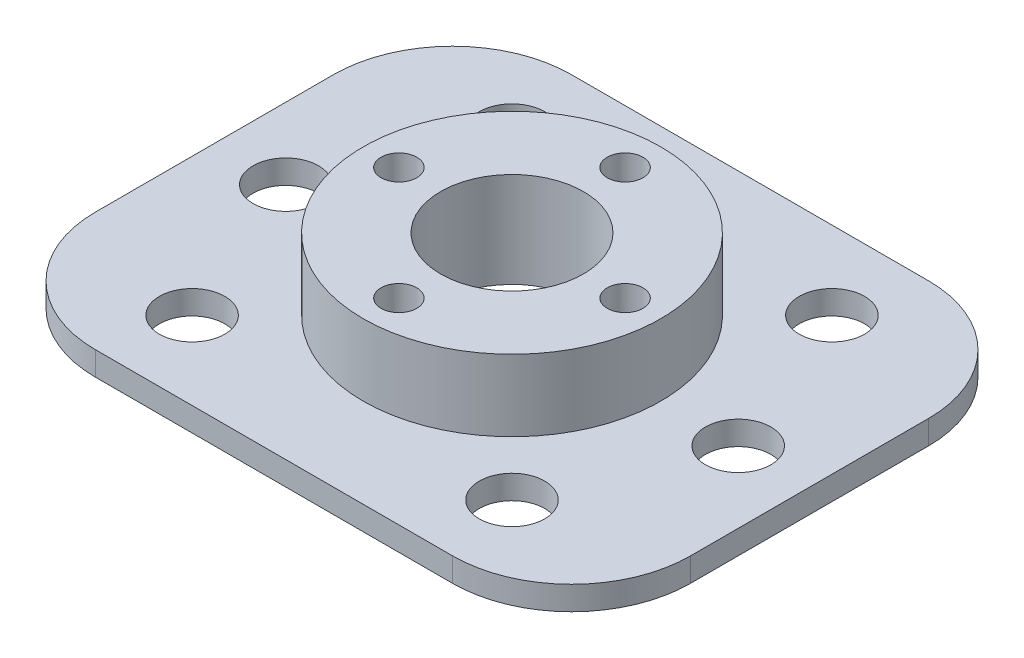
from build123d import *

# Parameters (mm, degrees)
SKETCH1_W           = 50
SKETCH1_H           = 40
SKETCH1_R           = 12.5
SKETCH1_R_2         = 2.75
SKETCH1_R_3         = 6
BOSS_EXTRUDE1_DEPTH = 2
SKETCH1_3_R         = 12.5
SKETCH1_3_R_2       = 6
BOSS_EXTRUDE2_DEPTH = 8
HOLE1_D             = 3
HOLE1_DEPTH         = 8
CIRPATTERN1_COUNT   = 4
FILLET1_R           = 10


with BuildPart() as part:
    # Sketch1 → Boss-Extrude1 (new body)
    with BuildSketch(Plane(origin=(0, 0, 0), x_dir=(1, 0, 0), z_dir=(0, 1, 0))):
        Rectangle(SKETCH1_W, SKETCH1_H)
        Circle(SKETCH1_R, mode=Mode.SUBTRACT)
        with Locations((-13.435028843, -13.435028843)):
            Circle(SKETCH1_R_2, mode=Mode.SUBTRACT)
        with Locations((-19, 0)):
            Circle(SKETCH1_R_2, mode=Mode.SUBTRACT)
        with Locations((-13.435028843, 13.435028843)):
            Circle(SKETCH1_R_2, mode=Mode.SUBTRACT)
        with Locations((13.435028843, 13.435028843)):
            Circle(SKETCH1_R_2, mode=Mode.SUBTRACT)
        with Locations((19, 0)):
            Circle(SKETCH1_R_2, mode=Mode.SUBTRACT)
        with Locations((13.435028843, -13.435028843)):
            Circle(SKETCH1_R_2, mode=Mode.SUBTRACT)
        Circle(SKETCH1_R)
        Circle(SKETCH1_R_3, mode=Mode.SUBTRACT)
    extrude(amount=BOSS_EXTRUDE1_DEPTH)

    # Sketch1_3 → Boss-Extrude2 (add)
    with BuildSketch(Plane(origin=(0, 0, 0), x_dir=(1, 0, 0), z_dir=(0, 1, 0))):
        Circle(SKETCH1_3_R)
        Circle(SKETCH1_3_R_2, mode=Mode.SUBTRACT)
    extrude(amount=BOSS_EXTRUDE2_DEPTH)

    # Hole1
    with Locations(Plane(origin=(0, 8, 0), x_dir=(1, 0, 0), z_dir=(0, 1, 0))):
        with Locations((0, -9.5)):
            hole1 = Hole(HOLE1_D / 2, depth=HOLE1_DEPTH)

    # CirPattern1: Hole1 ×4 about axis
    cirpattern1_axis = Axis((0, 0, 0), (0, 1, 0))
    for i in range(1, CIRPATTERN1_COUNT):
        add(hole1.rotate(cirpattern1_axis, i * 360 / CIRPATTERN1_COUNT), mode=Mode.SUBTRACT)

    # Fillet1
    fillet1_edges = [part.edges().sort_by_distance(p)[0] for p in [
        (25, 1, 20),
        (-25, 1, 20),
        (-25, 1, -20),
        (25, 1, -20),
    ]]
    fillet(fillet1_edges, radius=FILLET1_R)


solid = part.part
